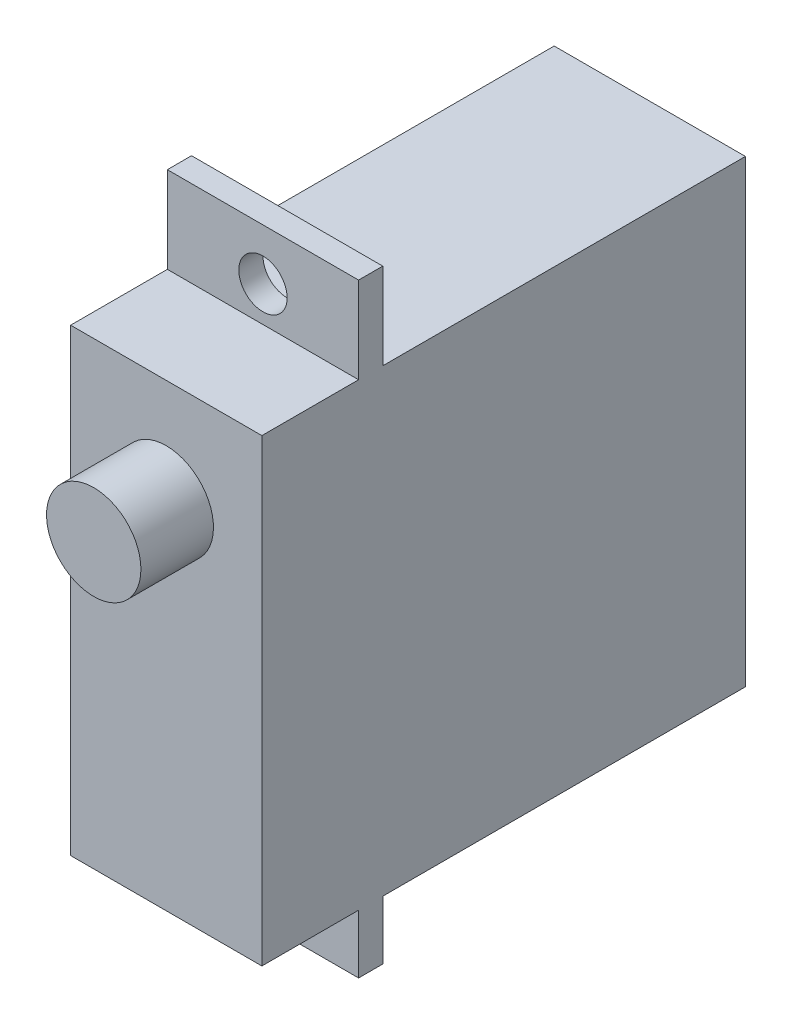
from build123d import *

# Parameters (mm, degrees)
SKETCH1_W           = 20
SKETCH1_H           = 19
BOSS_EXTRUDE1_DEPTH = 7.91
SKETCH2_W           = 1
SKETCH2_H           = 25
BOSS_EXTRUDE2_DEPTH = 7.91
SKETCH3_R           = 1
CUT_EXTRUDE1_DEPTH  = 21.9
SKETCH4_R           = 1.951580775
BOSS_EXTRUDE3_DEPTH = 3


with BuildPart() as part:
    # Sketch1 → Boss-Extrude1 (new body)
    with BuildSketch(Plane(origin=(0, 0, 0), x_dir=(0, 0, -1), z_dir=(1, 0, 0))):
        with Locations((-7.960008023, 6.124197801)):
            Rectangle(SKETCH1_W, SKETCH1_H)
    extrude(amount=BOSS_EXTRUDE1_DEPTH)

    # Sketch2 → Boss-Extrude2 (add)
    with BuildSketch(Plane(origin=(7.91, 0, 0), x_dir=(0, 0, -1), z_dir=(1, 0, 0))):
        with Locations((-13.460008023, 6.694520813)):
            Rectangle(SKETCH2_W, SKETCH2_H)
    extrude(amount=-BOSS_EXTRUDE2_DEPTH)

    # Sketch3 → Cut-Extrude1 (cut)
    with BuildSketch(Plane.XY.offset(13.960008023)):
        with Locations((3.955, 17.079197801)):
            Circle(SKETCH3_R)
        with Locations((3.955, -4.830802199)):
            Circle(SKETCH3_R)
    extrude(amount=-CUT_EXTRUDE1_DEPTH, mode=Mode.SUBTRACT)

    # Sketch4 → Boss-Extrude3 (add)
    with BuildSketch(Plane.XY.offset(17.960008023)):
        with Locations((3.955, 11.333194866)):
            Circle(SKETCH4_R)
    extrude(amount=BOSS_EXTRUDE3_DEPTH)


solid = part.part
